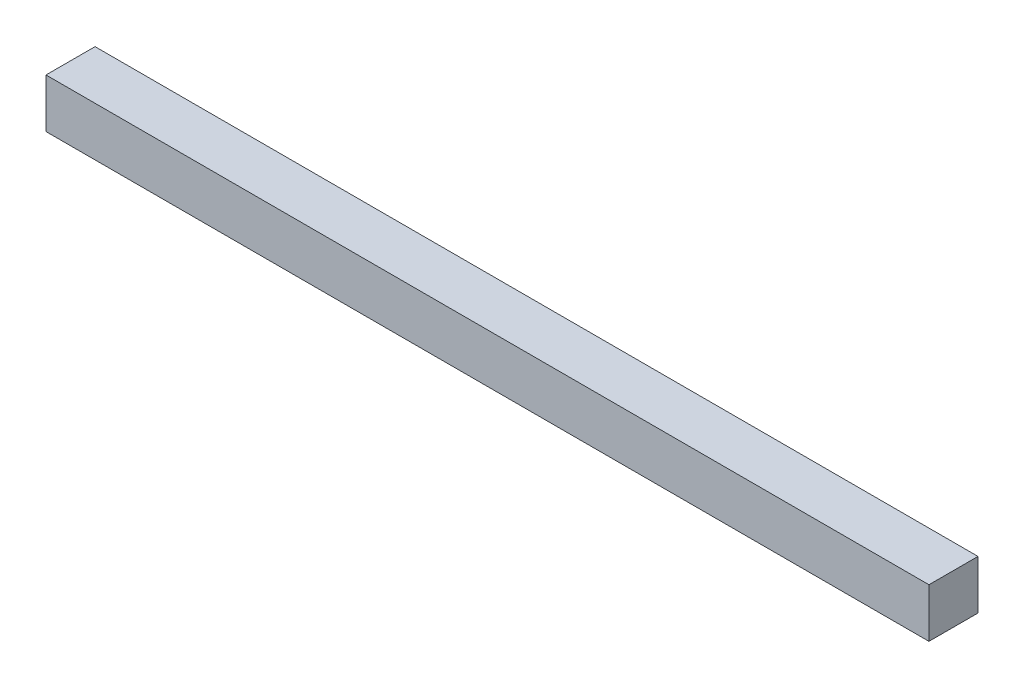
from build123d import *

# Parameters (mm, degrees)
SKETCH1_W           = 25.4
SKETCH1_H           = 25.4
BOSS_EXTRUDE1_DEPTH = 457.2


with BuildPart() as part:
    # Sketch1 → Boss-Extrude1 (new body)
    with BuildSketch(Plane(origin=(0, 0, 0), x_dir=(0, 0, -1), z_dir=(1, 0, 0))):
        with Locations((12.7, 12.7)):
            Rectangle(SKETCH1_W, SKETCH1_H)
    extrude(amount=BOSS_EXTRUDE1_DEPTH)


solid = part.part
